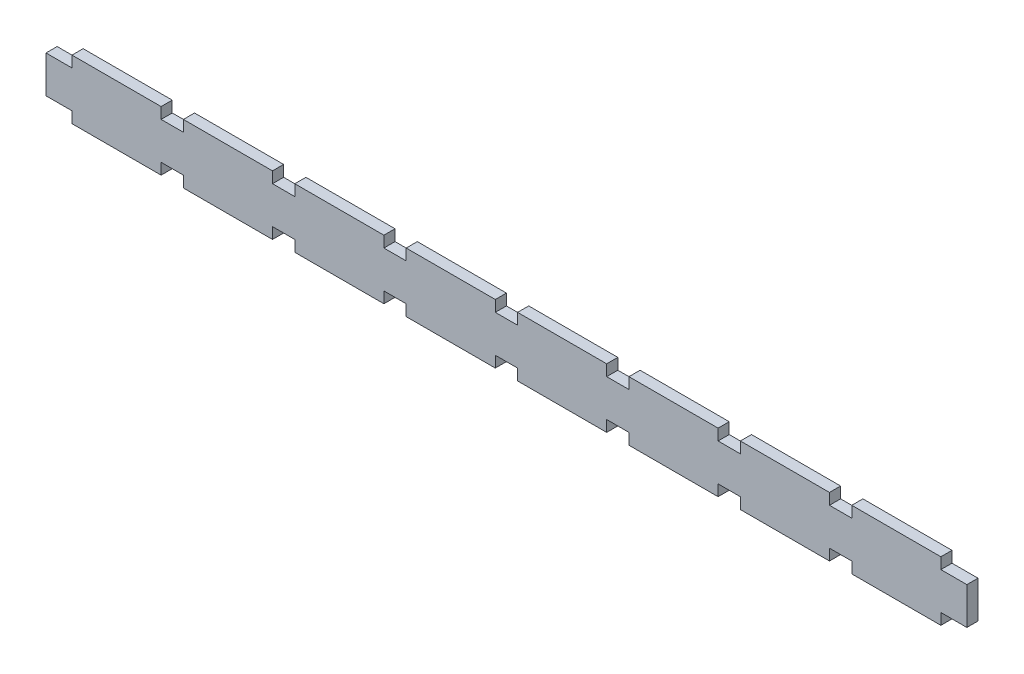
from build123d import *

# Parameters (mm, degrees)
BOSS_EXTRUDE1_DEPTH = 3


with BuildPart() as part:
    # Sketch1 → Boss-Extrude1 (new body)
    with BuildSketch(Plane(origin=(0, 0, 0), x_dir=(-1, 0, 0), z_dir=(0, 0, 1))):
        Polygon((545.787224347, 3), (545.787224347, 0), (521.787224347, 0), (521.787224347, 3), (515.787224347, 3), (515.787224347, 0), (491.787224347, 0), (491.787224347, 3), (485.787224347, 3), (485.787224347, 0), (461.787224347, 0), (461.787224347, 3), (455.787224347, 3), (455.787224347, 0), (431.787224347, 0), (431.787224347, 3), (425.787224347, 3), (425.787224347, 0), (401.787224347, 0), (401.787224347, 3), (395.787224347, 3), (395.787224347, 0), (371.787224347, 0), (371.787224347, 3), (365.787224347, 3), (365.787224347, 0), (341.787224347, 0), (341.787224347, 3), (335.787224347, 3), (335.787224347, 0), (311.787224347, 0), (311.787224347, 3), (304.787224347, 3), (304.787224347, 13), (311.787224347, 13), (311.787224347, 16), (335.787224347, 16), (335.787224347, 13), (341.787224347, 13), (341.787224347, 16), (365.787224347, 16), (365.787224347, 13), (371.787224347, 13), (371.787224347, 16), (395.787224347, 16), (395.787224347, 13), (401.787224347, 13), (401.787224347, 16), (425.787224347, 16), (425.787224347, 13), (431.787224347, 13), (431.787224347, 16), (455.787224347, 16), (455.787224347, 13), (461.787224347, 13), (461.787224347, 16), (485.787224347, 16), (485.787224347, 13), (491.787224347, 13), (491.787224347, 16), (515.787224347, 16), (515.787224347, 13), (521.787224347, 13), (521.787224347, 16), (545.787224347, 16), (545.787224347, 13), (552.787224347, 13), (552.787224347, 3), align=None)
    extrude(amount=BOSS_EXTRUDE1_DEPTH)


solid = part.part
